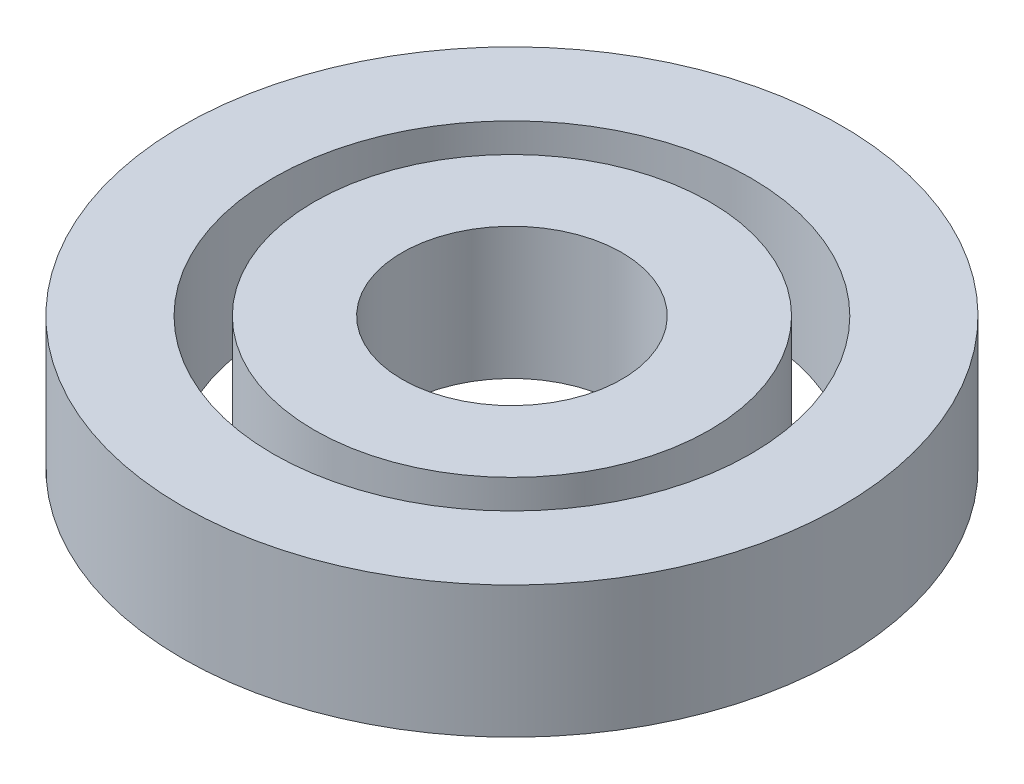
from build123d import *

# Parameters (mm, degrees)
SKETCH1_R           = 18
SKETCH1_R_2         = 10
BOSS_EXTRUDE1_DEPTH = 12
SKETCH2_R           = 30
SKETCH2_R_2         = 21.75
BOSS_EXTRUDE2_DEPTH = 12


with BuildPart() as part:
    # Sketch1 → Boss-Extrude1 (new body)
    with BuildSketch(Plane(origin=(0, 0, 0), x_dir=(1, 0, 0), z_dir=(0, 1, 0))):
        Circle(SKETCH1_R)
        Circle(SKETCH1_R_2, mode=Mode.SUBTRACT)
    extrude(amount=BOSS_EXTRUDE1_DEPTH)


with BuildPart() as body_2:
    # Sketch2 → Boss-Extrude2 (new body)
    with BuildSketch(Plane(origin=(0, 0, 0), x_dir=(1, 0, 0), z_dir=(0, 1, 0))):
        Circle(SKETCH2_R)
        Circle(SKETCH2_R_2, mode=Mode.SUBTRACT)
    extrude(amount=BOSS_EXTRUDE2_DEPTH)


solid = Compound([part.part, body_2.part])
